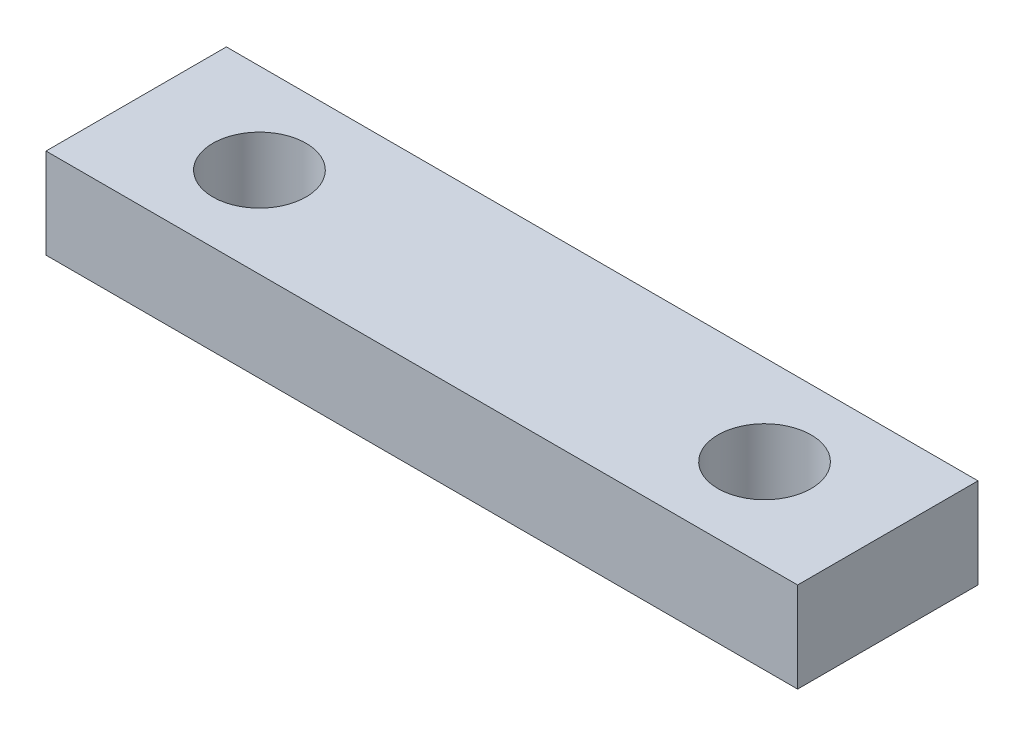
from build123d import *

# Parameters (mm, degrees)
SKETCH1_W           = 25
SKETCH1_H           = 6
SKETCH1_R           = 1.55
BOSS_EXTRUDE1_DEPTH = 3


with BuildPart() as part:
    # Sketch1 → Boss-Extrude1 (new body)
    with BuildSketch(Plane(origin=(0, 0, 0), x_dir=(1, 0, 0), z_dir=(0, 1, 0))):
        Rectangle(SKETCH1_W, SKETCH1_H)
        with Locations((-8.4, 0)):
            Circle(SKETCH1_R, mode=Mode.SUBTRACT)
        with Locations((8.4, 0)):
            Circle(SKETCH1_R, mode=Mode.SUBTRACT)
    extrude(amount=BOSS_EXTRUDE1_DEPTH)


solid = part.part
